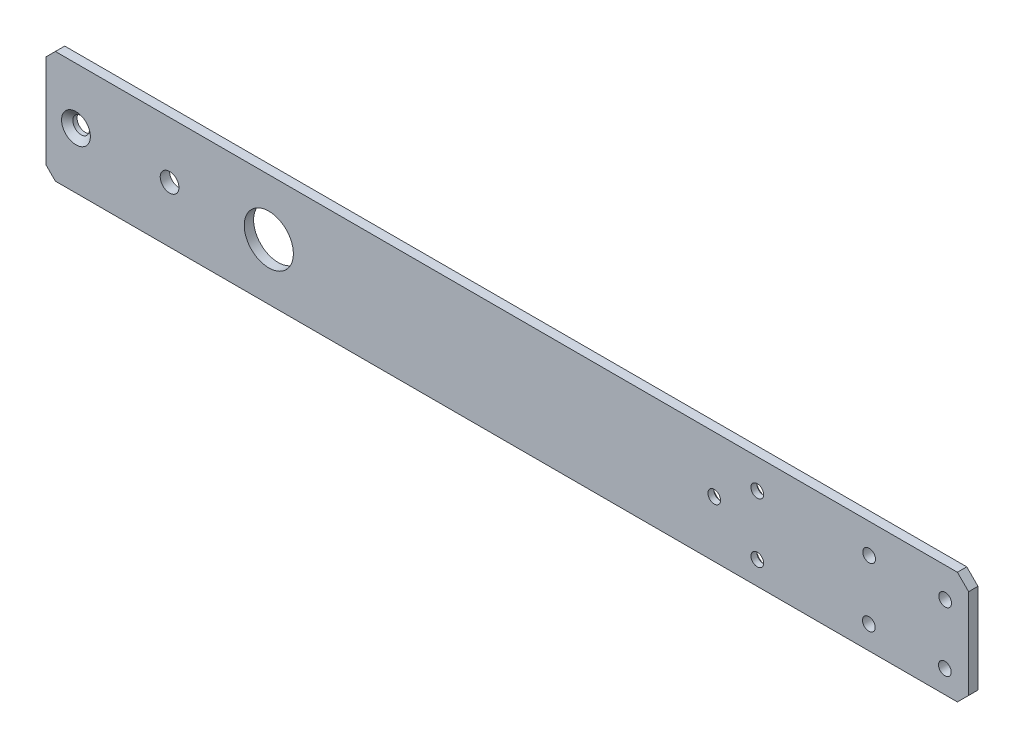
from build123d import *

# Parameters (mm, degrees)
SKETCH1_R                                         = 8.334375
BOSS_EXTRUDE1_DEPTH                               = 1.5875
F_6_CLEARANCE_HOLE3_D                             = 4.3053
CUT_EXTRUDE1_DEPTH                                = 4.175
CHAMFER1_SIZE                                     = 3.81
SKETCH10_W                                        = 50.8
SKETCH10_H                                        = 38.1
BOSS_EXTRUDE2_DEPTH                               = 3.175
CHAMFER2_SIZE                                     = 3.175
F_1_4_0_25_DIAMETER_HOLE1_D                       = 6.35
CSK_FOR_6_FLAT_HEAD_MACHINE_SCREW_100_D           = 4.3053
CSK_FOR_6_FLAT_HEAD_MACHINE_SCREW_100_CSINK_D     = 7.0866
CSK_FOR_6_FLAT_HEAD_MACHINE_SCREW_100_CSINK_ANGLE = 100


with BuildPart() as part:
    # Sketch1 → Boss-Extrude1 (new body, symmetric)
    with BuildSketch(Plane.XY):
        Polygon((0, 19.05), (-28.575, 19.05), (-28.575, -19.05), (0, -19.05), (247.281942035, -19.05), (254, 19.05), align=None)
        Circle(SKETCH1_R, mode=Mode.SUBTRACT)
    extrude(amount=BOSS_EXTRUDE1_DEPTH, both=True)

    # #6 Clearance Hole3 (through all)
    with Locations(Plane.XY.offset(1.5875)):
        with Locations((229.388701471, 8.923791784), (229.282371239, -11.346798968), (203.503161764, -11.143926969), (203.608782335, 8.991375351), (165.672159691, 8.991375351), (165.672159691, -11.143926969), (151.067159691, 0)):
            Hole(F_6_CLEARANCE_HOLE3_D / 2)

    # Sketch9 → Cut-Extrude1 (cut, through all)
    with BuildSketch(Plane.XY.offset(1.5875)):
        Polygon((254, 19.05), (247.281942035, -19.05), (237.352085197, -19.05), (237.352085197, 19.05), align=None)
    extrude(amount=-CUT_EXTRUDE1_DEPTH, mode=Mode.SUBTRACT)

    # Chamfer1
    chamfer1_edges = [part.edges().sort_by_distance(p)[0] for p in [
        (-28.575, -19.05, 0),
        (-28.575, 19.05, 0),
        (237.352085197, 19.05, 0),
        (237.352085197, -19.05, 0),
    ]]
    chamfer(chamfer1_edges, length=CHAMFER1_SIZE)

    # Sketch10 → Boss-Extrude2 (add, through all)
    with BuildSketch(Plane.XY.offset(1.5875)):
        with Locations((-50.165, 0)):
            Rectangle(SKETCH10_W, SKETCH10_H)
    extrude(amount=-BOSS_EXTRUDE2_DEPTH)

    # Chamfer2
    chamfer2_edges = [part.edges().sort_by_distance(p)[0] for p in [
        (-75.565, -19.05, 0),
        (-75.565, 19.05, 0),
    ]]
    chamfer(chamfer2_edges, length=CHAMFER2_SIZE)

    # Sketch12 → CSK for #10 Flat Head Machine Screw (100)1 (revolve, cut)
    with BuildSketch(Plane(origin=(-65.405, 0, 1.5875), x_dir=(0, -1, 0), z_dir=(1, 0, 0))):
        Polygon((0, 0), (0, 3.175), (2.8067, 3.175), (2.8067, 1.747676712), (4.8895, 0), align=None)
    revolve(axis=Axis((-65.405, 0, 7.9375), (0, 0, -1)), mode=Mode.SUBTRACT)

    # 1/4 (0.25) Diameter Hole1 (through all)
    with Locations(Plane.XY.offset(1.5875)):
        with Locations((-33.655, 0)):
            Hole(F_1_4_0_25_DIAMETER_HOLE1_D / 2)

    # CSK for #6 Flat Head Machine Screw (100)1 (through all)
    with Locations(Plane(origin=(0, 0, -1.5875), x_dir=(-1, 0, 0), z_dir=(0, 0, -1))):
        with Locations((-151.067159691, 0), (-165.672159691, -11.143926969), (-165.672159691, 8.991375351)):
            CounterSinkHole(CSK_FOR_6_FLAT_HEAD_MACHINE_SCREW_100_D / 2, CSK_FOR_6_FLAT_HEAD_MACHINE_SCREW_100_CSINK_D / 2, counter_sink_angle=CSK_FOR_6_FLAT_HEAD_MACHINE_SCREW_100_CSINK_ANGLE)


solid = part.part
